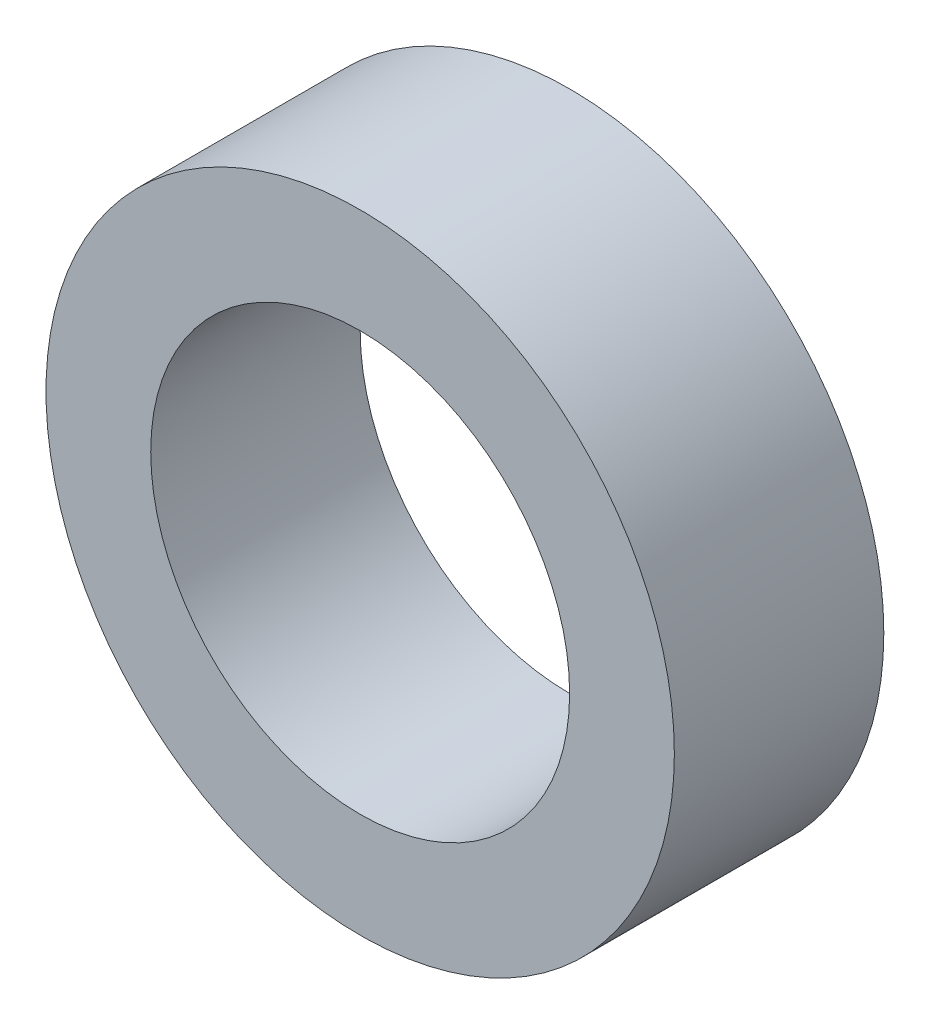
from build123d import *

# Parameters (mm, degrees)
SKETCH1_R           = 15
SKETCH1_R_2         = 10
BOSS_EXTRUDE1_DEPTH = 10


with BuildPart() as part:
    # Sketch1 → Boss-Extrude1 (new body)
    with BuildSketch(Plane.XY):
        Circle(SKETCH1_R)
        Circle(SKETCH1_R_2, mode=Mode.SUBTRACT)
    extrude(amount=BOSS_EXTRUDE1_DEPTH)


solid = part.part
